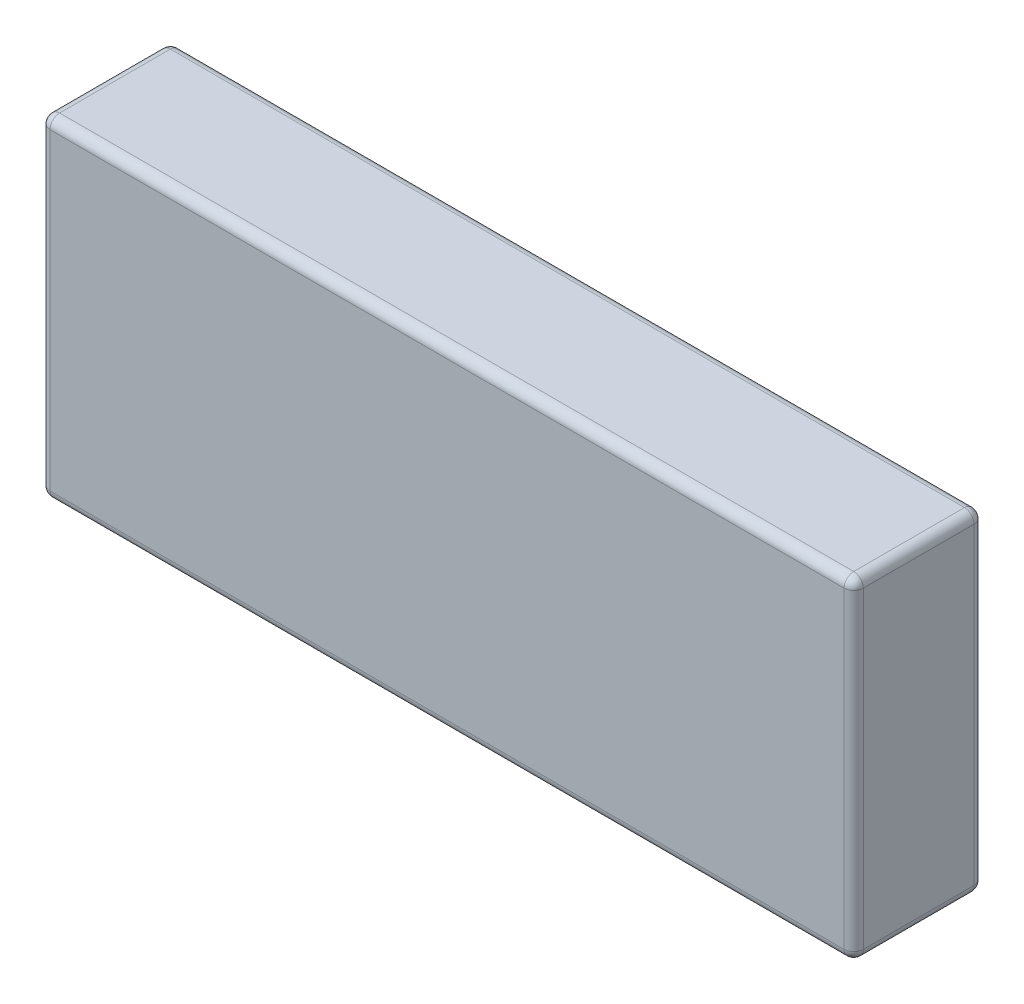
from build123d import *

# Parameters (mm, degrees)
SKETCH1_W           = 169
SKETCH1_H           = 27
BOSS_EXTRUDE1_DEPTH = 69
FILLET1_R           = 2


with BuildPart() as part:
    # Sketch1 → Boss-Extrude1 (new body)
    with BuildSketch(Plane(origin=(0, 0, 0), x_dir=(1, 0, 0), z_dir=(0, 1, 0))):
        with Locations((84.5, 13.5)):
            Rectangle(SKETCH1_W, SKETCH1_H)
    extrude(amount=BOSS_EXTRUDE1_DEPTH)

    # Fillet1
    fillet1_edges = [part.edges().sort_by_distance(p)[0] for p in [
        (169, 69, -13.5),
        (84.5, 69, -27),
        (0, 69, -13.5),
        (84.5, 0, -27),
        (169, 0, -13.5),
        (84.5, 0, 0),
        (0, 0, -13.5),
        (84.5, 69, 0),
        (0, 34.5, -27),
        (169, 34.5, -27),
        (169, 34.5, 0),
        (0, 34.5, 0),
    ]]
    fillet(fillet1_edges, radius=FILLET1_R)


solid = part.part
